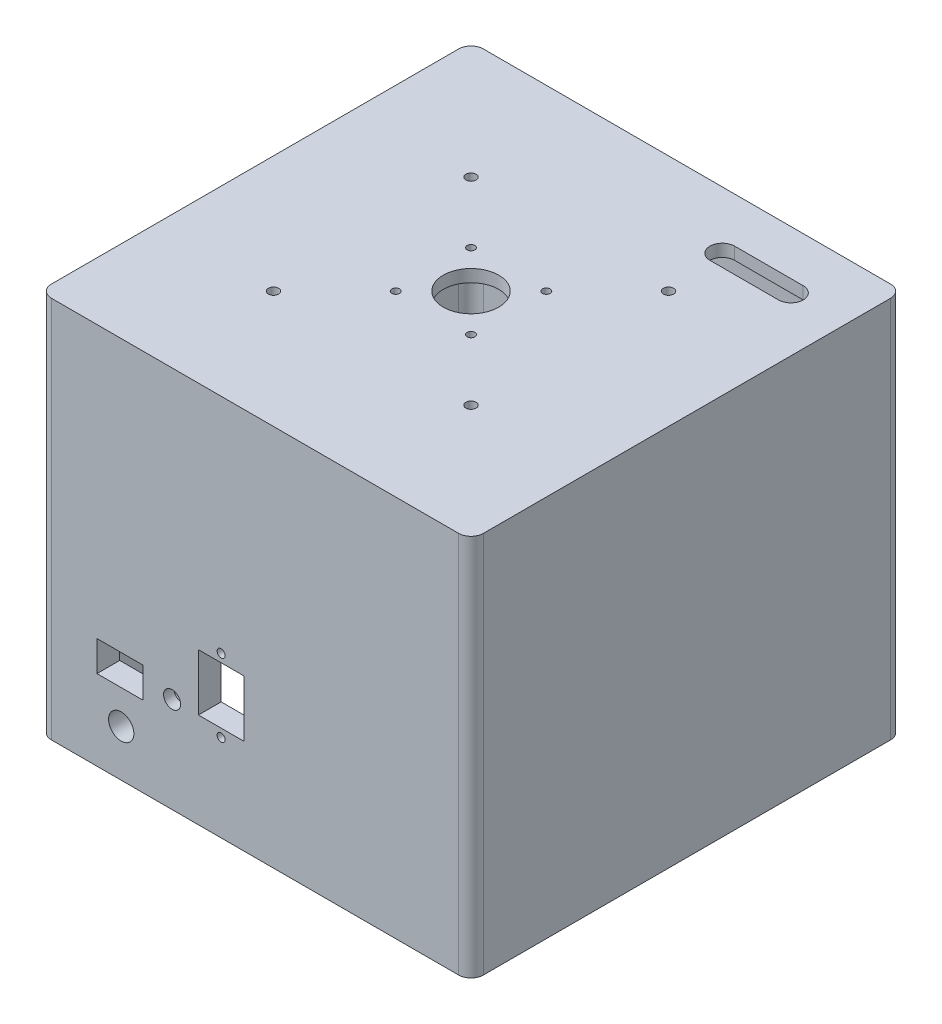
from build123d import *

# Parameters (mm, degrees)
SKETCH1_W                = 159.078855478
SKETCH1_H                = 159.078855478
BOSS_EXTRUDE1_DEPTH      = 101.6
BOSS_EXTRUDE1_DEPTH_BACK = 50.8
BOSS_EXTRUDE3_START      = 101.6
SKETCH1_5_R              = 11.43
BOSS_EXTRUDE3_DEPTH      = 5.08
SKETCH3_R                = 1.6
CUT_EXTRUDE1_DEPTH       = 202.510224058
FILLET4_R                = 5.08
SKETCH4_R                = 2.1
CUT_EXTRUDE2_DEPTH       = 5.08
SKETCH5_R                = 3.5
SKETCH5_R_2              = 5.207
SKETCH5_R_3              = 1.65
SKETCH5_W                = 19
SKETCH5_H                = 12.5
SKETCH5_W_2              = 18.7
SKETCH5_H_2              = 23.3
CUT_EXTRUDE3_DEPTH       = 9.360572261
SKETCH7_W                = 25.4
SKETCH7_H                = 5.08
CUT_EXTRUDE4_DEPTH       = 5.588
BOSS_EXTRUDE4_DEPTH      = 25.4
CUT_EXTRUDE5_DEPTH       = 25.4
SKETCH11_W               = 12.7
SKETCH11_H               = 4.572
CUT_EXTRUDE6_DEPTH       = 5.334
CUT_EXTRUDE7_DEPTH       = 2.54
CUT_EXTRUDE8_DEPTH       = 16.764
SKETCH13_R               = 6.5
CUT_EXTRUDE9_DEPTH       = 5.08


with BuildPart() as part:
    # Sketch1 → Boss-Extrude1 (new, two sides)
    with BuildSketch(Plane(origin=(0, 0, 0), x_dir=(1, 0, 0), z_dir=(0, 1, 0))) as boss_extrude1_sk:
        with BuildLine():
            Line((-83.82, -88.9), (83.82, -88.9))
            ThreePointArc((83.82, -88.9), (87.412102448, -87.412102448), (88.9, -83.82))
            Line((88.9, -83.82), (88.9, 83.82))
            ThreePointArc((88.9, 83.82), (87.412102448, 87.412102448), (83.82, 88.9))
            Line((83.82, 88.9), (-83.82, 88.9))
            ThreePointArc((-83.82, 88.9), (-87.412102448, 87.412102448), (-88.9, 83.82))
            Line((-88.9, 83.82), (-88.9, -83.82))
            ThreePointArc((-88.9, -83.82), (-87.412102448, -87.412102448), (-83.82, -88.9))
        make_face()
        Rectangle(SKETCH1_W, SKETCH1_H, mode=Mode.SUBTRACT)
    extrude(amount=BOSS_EXTRUDE1_DEPTH)
    extrude(boss_extrude1_sk.sketch, amount=-BOSS_EXTRUDE1_DEPTH_BACK)

    # Sketch1_5 → Boss-Extrude3 (add)
    with BuildSketch(Plane(origin=(0, 0, 0), x_dir=(1, 0, 0), z_dir=(0, 1, 0)).offset(BOSS_EXTRUDE3_START)):
        with BuildLine():
            ThreePointArc((-88.9, -83.82), (-87.412102448, -87.412102448), (-83.82, -88.9))
            Line((-83.82, -88.9), (83.82, -88.9))
            ThreePointArc((83.82, -88.9), (87.412102448, -87.412102448), (88.9, -83.82))
            Line((88.9, -83.82), (88.9, 83.82))
            ThreePointArc((88.9, 83.82), (87.412102448, 87.412102448), (83.82, 88.9))
            Line((83.82, 88.9), (-83.82, 88.9))
            ThreePointArc((-83.82, 88.9), (-87.412102448, 87.412102448), (-88.9, 83.82))
            Line((-88.9, 83.82), (-88.9, -83.82))
        make_face()
        with Locations(Location((0, 0, 0), (0, 0, 270))):
            Circle(SKETCH1_5_R, mode=Mode.SUBTRACT)
    extrude(amount=BOSS_EXTRUDE3_DEPTH)

    # Sketch3 → Cut-Extrude1 (cut, through all)
    with BuildSketch(Plane(origin=(0, 106.68, 0), x_dir=(1, 0, 0), z_dir=(0, 1, 0))):
        with Locations(Location((-15.5, 15.5, 0), (0, 0, 270))):
            Circle(SKETCH3_R)
        with Locations(Location((-15.5, -15.5, 0), (0, 0, 270))):
            Circle(SKETCH3_R)
        with Locations(Location((15.5, 15.5, 0), (0, 0, 270))):
            Circle(SKETCH3_R)
        with Locations(Location((15.5, -15.5, 0), (0, 0, 270))):
            Circle(SKETCH3_R)
    extrude(amount=-CUT_EXTRUDE1_DEPTH, mode=Mode.SUBTRACT)

    # Fillet4
    fillet4_edges = [part.edges().sort_by_distance(p)[0] for p in [
        (79.539427739, 25.4, -79.539427739),
        (-79.539427739, 25.4, -79.539427739),
        (-79.539427739, 25.4, 79.539427739),
        (79.539427739, 25.4, 79.539427739),
    ]]
    fillet(fillet4_edges, radius=FILLET4_R)

    # Sketch4 → Cut-Extrude2 (cut)
    with BuildSketch(Plane(origin=(0, 106.68, 0), x_dir=(1, 0, 0), z_dir=(0, 1, 0))):
        with Locations(Location((-40.66, 40.66, 0), (0, 0, 270))):
            Circle(SKETCH4_R)
        with Locations(Location((40.66, 40.66, 0), (0, 0, 270))):
            Circle(SKETCH4_R)
        with Locations(Location((-40.66, -40.66, 0), (0, 0, 270))):
            Circle(SKETCH4_R)
        with Locations(Location((40.66, -40.66, 0), (0, 0, 270))):
            Circle(SKETCH4_R)
    extrude(amount=-CUT_EXTRUDE2_DEPTH, mode=Mode.SUBTRACT)

    # Sketch5 → Cut-Extrude3 (cut)
    with BuildSketch(Plane.XY.offset(88.9)):
        with Locations((-34.158642562, -11.51833892)):
            Circle(SKETCH5_R)
        with Locations((-55.102312512, -31.62532479)):
            Circle(SKETCH5_R_2)
        with Locations((-13.97, 15.0114)):
            Circle(SKETCH5_R_3)
        with Locations((-13.97, -15.0114)):
            Circle(SKETCH5_R_3)
        with Locations((-55.584910431, -11.51833892)):
            Rectangle(SKETCH5_W, SKETCH5_H)
        with Locations((-13.97, 0)):
            Rectangle(SKETCH5_W_2, SKETCH5_H_2)
    extrude(amount=-CUT_EXTRUDE3_DEPTH, mode=Mode.SUBTRACT)

    # Sketch7 → Cut-Extrude4 (cut)
    with BuildSketch(Plane.XZ.offset(50.8)):
        with Locations((0, -82.079427739)):
            Rectangle(SKETCH7_W, SKETCH7_H)
    extrude(amount=-CUT_EXTRUDE4_DEPTH, mode=Mode.SUBTRACT)

    # Sketch10 → Boss-Extrude4 (add)
    with BuildSketch(Plane.ZY.offset(-12.7)):
        Polygon((-79.539427739, -38.354), (-79.539427739, -41.148), (-81.063427739, -41.148), align=None)
    extrude(amount=BOSS_EXTRUDE4_DEPTH)

    # Sketch10_2 → Cut-Extrude5 (cut)
    with BuildSketch(Plane.ZY.offset(-12.7)):
        Polygon((-79.539427739, -38.354), (-79.539427739, -41.148), (-81.063427739, -41.148), align=None)
    extrude(amount=CUT_EXTRUDE5_DEPTH, mode=Mode.SUBTRACT)

    # Sketch11 → Cut-Extrude6 (cut)
    with BuildSketch(Plane(origin=(0, 0, 79.539427739), x_dir=(-1, 0, 0), z_dir=(0, 0, -1))):
        with Locations((-44.45, -43.434)):
            Rectangle(SKETCH11_W, SKETCH11_H)
        with Locations((44.45, -43.434)):
            Rectangle(SKETCH11_W, SKETCH11_H)
    extrude(amount=-CUT_EXTRUDE6_DEPTH, mode=Mode.SUBTRACT)

    # Sketch12 → Cut-Extrude7 (cut)
    with BuildSketch(Plane(origin=(0, 106.68, 0), x_dir=(1, 0, 0), z_dir=(0, 1, 0))):
        with BuildLine():
            Line((38.210330331, 70.326189438), (66.435994121, 70.326189438))
            ThreePointArc((66.435994121, 70.326189438), (71.515994121, 65.246189438), (66.435994121, 60.166189438))
            Line((66.435994121, 60.166189438), (38.210330331, 60.166189438))
            ThreePointArc((38.210330331, 60.166189438), (33.130330331, 65.246189438), (38.210330331, 70.326189438))
        make_face()
    extrude(amount=-CUT_EXTRUDE7_DEPTH, mode=Mode.SUBTRACT)

    # Sketch12_2 → Cut-Extrude8 (cut)
    with BuildSketch(Plane(origin=(0, 106.68, 0), x_dir=(1, 0, 0), z_dir=(0, 1, 0))):
        with BuildLine():
            Line((38.210330331, 70.326189438), (66.435994121, 70.326189438))
            ThreePointArc((66.435994121, 70.326189438), (71.515994121, 65.246189438), (66.435994121, 60.166189438))
            Line((66.435994121, 60.166189438), (38.210330331, 60.166189438))
            ThreePointArc((38.210330331, 60.166189438), (33.130330331, 65.246189438), (38.210330331, 70.326189438))
        make_face()
    extrude(amount=-CUT_EXTRUDE8_DEPTH, mode=Mode.SUBTRACT)

    # Sketch13 → Cut-Extrude9 (cut)
    with BuildSketch(Plane(origin=(0, 0, 79.539427739), x_dir=(-1, 0, 0), z_dir=(0, 0, -1))):
        with Locations((34.158642562, -11.51833892)):
            Circle(SKETCH13_R)
    extrude(amount=-CUT_EXTRUDE9_DEPTH, mode=Mode.SUBTRACT)


solid = part.part
